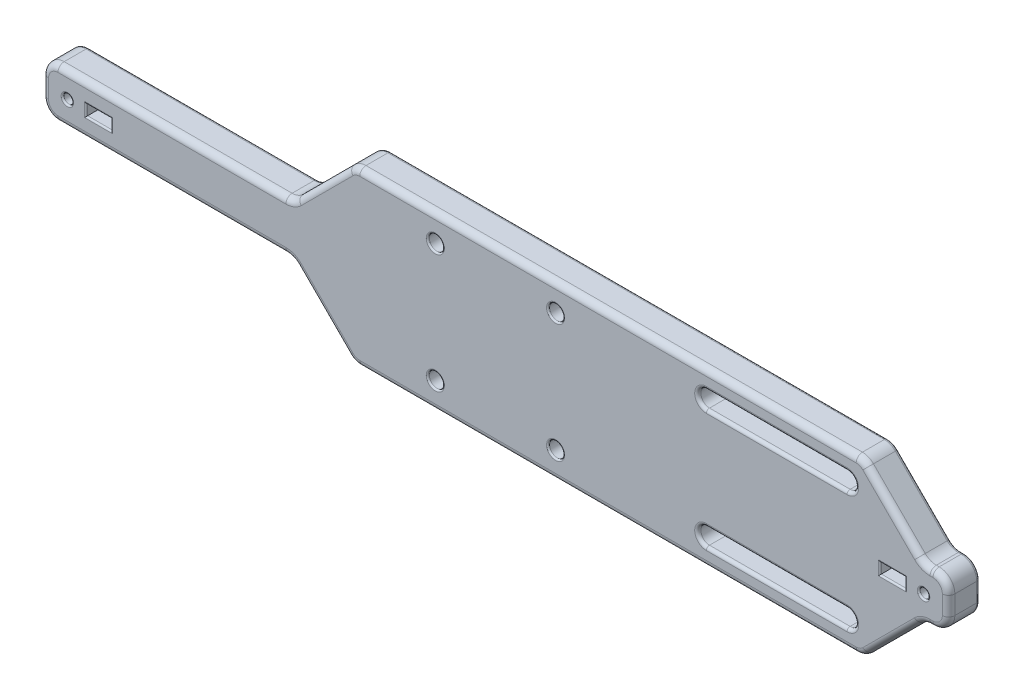
from build123d import *

# Parameters (mm, degrees)
SKETCH1_W           = 290
SKETCH1_H           = 55
BOSS_EXTRUDE1_DEPTH = 10
SKETCH2_R           = 2.4
CUT_EXTRUDE1_DEPTH  = 8
CUT_EXTRUDE2_REACH  = 12
CUT_EXTRUDE3_REACH  = 12
SKETCH6_R           = 1.5
CUT_EXTRUDE4_REACH  = 12
SKETCH8_R           = 2
CUT_EXTRUDE5_DEPTH  = 8
SKETCH10_R          = 3
CUT_EXTRUDE6_DEPTH  = 6
SKETCH11_W          = 8
SKETCH11_H          = 3.5
CUT_EXTRUDE7_DEPTH  = 5
FILLET2_R           = 5
FILLET3_R           = 0.5
FILLET4_R           = 2
FILLET5_R           = 1


with BuildPart() as part:
    # Sketch1 → Boss-Extrude1 (new body)
    with BuildSketch(Plane.XY):
        Rectangle(SKETCH1_W, SKETCH1_H)
    extrude(amount=BOSS_EXTRUDE1_DEPTH)

    # Sketch2 → Cut-Extrude1 (cut)
    with BuildSketch(Plane.XY.offset(10)):
        with Locations((-19.25, 19)):
            Circle(SKETCH2_R)
        with Locations((19.25, 19)):
            Circle(SKETCH2_R)
        with Locations((19.25, -19)):
            Circle(SKETCH2_R)
        with Locations((-19.25, -19)):
            Circle(SKETCH2_R)
    extrude(amount=-CUT_EXTRUDE1_DEPTH, mode=Mode.SUBTRACT)

    # Sketch5 → Cut-Extrude2 (cut, up to next)
    with BuildSketch(Plane.XY.offset(10), mode=Mode.PRIVATE) as cut_extrude2_sk1:
        with BuildLine():
            Line((67.5, 21.75), (112.5, 21.75))
            ThreePointArc((112.5, 21.75), (115.25, 19), (112.5, 16.25))
            Line((112.5, 16.25), (67.5, 16.25))
            ThreePointArc((67.5, 16.25), (64.75, 19), (67.5, 21.75))
        make_face()
    cut_extrude2_tool1 = extrude(cut_extrude2_sk1.sketch, amount=-CUT_EXTRUDE2_REACH, mode=Mode.PRIVATE) & part.part
    add(cut_extrude2_tool1.solids().sort_by_distance((90, 19, 10))[0], mode=Mode.SUBTRACT)
    # Sketch5 → Cut-Extrude2 (cut, up to next)
    with BuildSketch(Plane.XY.offset(10), mode=Mode.PRIVATE) as cut_extrude2_sk2:
        with BuildLine():
            Line((67.5, -21.75), (112.5, -21.75))
            ThreePointArc((112.5, -21.75), (115.25, -19), (112.5, -16.25))
            Line((112.5, -16.25), (67.5, -16.25))
            ThreePointArc((67.5, -16.25), (64.75, -19), (67.5, -21.75))
        make_face()
    cut_extrude2_tool2 = extrude(cut_extrude2_sk2.sketch, amount=-CUT_EXTRUDE2_REACH, mode=Mode.PRIVATE) & part.part
    add(cut_extrude2_tool2.solids().sort_by_distance((90, -19, 10))[0], mode=Mode.SUBTRACT)

    # Sketch6 → Cut-Extrude3 (cut, up to next)
    with BuildSketch(Plane.XY.offset(10), mode=Mode.PRIVATE) as cut_extrude3_sk1:
        with Locations((137, 0)):
            Circle(SKETCH6_R)
    cut_extrude3_tool1 = extrude(cut_extrude3_sk1.sketch, amount=-CUT_EXTRUDE3_REACH, mode=Mode.PRIVATE) & part.part
    add(cut_extrude3_tool1.solids().sort_by_distance((137, 0, 10))[0], mode=Mode.SUBTRACT)
    # Sketch6 → Cut-Extrude3 (cut, up to next)
    with BuildSketch(Plane.XY.offset(10), mode=Mode.PRIVATE) as cut_extrude3_sk2:
        with Locations((-137, 0)):
            Circle(SKETCH6_R)
    cut_extrude3_tool2 = extrude(cut_extrude3_sk2.sketch, amount=-CUT_EXTRUDE3_REACH, mode=Mode.PRIVATE) & part.part
    add(cut_extrude3_tool2.solids().sort_by_distance((-137, 0, 10))[0], mode=Mode.SUBTRACT)

    # Sketch7 → Cut-Extrude4 (cut, up to next)
    with BuildSketch(Plane.XY.offset(10), mode=Mode.PRIVATE) as cut_extrude4_sk1:
        Polygon((-145, 8), (-65, 8), (-45.5, 27.5), (-145, 27.5), align=None)
    cut_extrude4_tool1 = extrude(cut_extrude4_sk1.sketch, amount=-CUT_EXTRUDE4_REACH, mode=Mode.PRIVATE) & part.part
    add(cut_extrude4_tool1.solids().sort_by_distance((-99.948468, 18.103064, 10))[0], mode=Mode.SUBTRACT)
    # Sketch7 → Cut-Extrude4 (cut, up to next)
    with BuildSketch(Plane.XY.offset(10), mode=Mode.PRIVATE) as cut_extrude4_sk2:
        Polygon((-65, -8), (-45.5, -27.5), (-145, -27.5), (-145, -8), align=None)
    cut_extrude4_tool2 = extrude(cut_extrude4_sk2.sketch, amount=-CUT_EXTRUDE4_REACH, mode=Mode.PRIVATE) & part.part
    add(cut_extrude4_tool2.solids().sort_by_distance((-99.948468, -18.103064, 10))[0], mode=Mode.SUBTRACT)
    # Sketch7 → Cut-Extrude4 (cut, up to next)
    with BuildSketch(Plane.XY.offset(10), mode=Mode.PRIVATE) as cut_extrude4_sk3:
        Polygon((117.5, 27.5), (137, 8), (145, 8), (145, 27.5), align=None)
    cut_extrude4_tool3 = extrude(cut_extrude4_sk3.sketch, amount=-CUT_EXTRUDE4_REACH, mode=Mode.PRIVATE) & part.part
    add(cut_extrude4_tool3.solids().sort_by_distance((135.232394, 19.535211, 10))[0], mode=Mode.SUBTRACT)
    # Sketch7 → Cut-Extrude4 (cut, up to next)
    with BuildSketch(Plane.XY.offset(10), mode=Mode.PRIVATE) as cut_extrude4_sk4:
        Polygon((117.5, -27.5), (145, -27.5), (145, -8), (137, -8), align=None)
    cut_extrude4_tool4 = extrude(cut_extrude4_sk4.sketch, amount=-CUT_EXTRUDE4_REACH, mode=Mode.PRIVATE) & part.part
    add(cut_extrude4_tool4.solids().sort_by_distance((135.232394, -19.535211, 10))[0], mode=Mode.SUBTRACT)

    # Sketch8 → Cut-Extrude5 (cut)
    with BuildSketch(Plane(origin=(0, 0, 0), x_dir=(-1, 0, 0), z_dir=(0, 0, -1))):
        with Locations((35, 15)):
            Circle(SKETCH8_R)
        with Locations((35, -15)):
            Circle(SKETCH8_R)
        with Locations((-35, -15)):
            Circle(SKETCH8_R)
        with Locations((-35, 15)):
            Circle(SKETCH8_R)
    extrude(amount=-CUT_EXTRUDE5_DEPTH, mode=Mode.SUBTRACT)

    # Sketch10 → Cut-Extrude6 (cut)
    with BuildSketch(Plane(origin=(0, 0, 0), x_dir=(-1, 0, 0), z_dir=(0, 0, -1))):
        with Locations((-137, 0)):
            Circle(SKETCH10_R)
        with Locations((137, 0)):
            Circle(SKETCH10_R)
    extrude(amount=-CUT_EXTRUDE6_DEPTH, mode=Mode.SUBTRACT)

    # Sketch11 → Cut-Extrude7 (cut)
    with BuildSketch(Plane.XY.offset(10)):
        with Locations((-127, 0)):
            Rectangle(SKETCH11_W, SKETCH11_H)
        with Locations((127, 0)):
            Rectangle(SKETCH11_W, SKETCH11_H)
    extrude(amount=-CUT_EXTRUDE7_DEPTH, mode=Mode.SUBTRACT)

    # Fillet2
    fillet2_edges = [part.edges().sort_by_distance(p)[0] for p in [
        (117.5, -27.5, 5),
        (137, -8, 5),
        (145, -8, 5),
        (-145, 8, 5),
        (-45.5, 27.5, 5),
        (-65, 8, 5),
        (-145, -8, 5),
        (-65, -8, 5),
        (-45.5, -27.5, 5),
        (117.5, 27.5, 5),
        (145, 8, 5),
        (137, 8, 5),
    ]]
    fillet(fillet2_edges, radius=FILLET2_R)

    # Fillet3
    fillet3_edges = [part.edges().sort_by_distance(p)[0] for p in [
        (37, 15, 0),
        (37, -15, 0),
        (-33, -15, 0),
        (-33, 15, 0),
        (140, 0, 0),
        (135.5, 0, 6),
        (-134, 0, 0),
        (-138.5, 0, 6),
        (-123, 0, 10),
        (-127, 1.75, 10),
        (-131, 0, 10),
        (-127, -1.75, 10),
        (131, 0, 10),
        (127, 1.75, 10),
        (123, 0, 10),
        (127, -1.75, 10),
        (-21.65, -19, 10),
        (16.85, -19, 10),
        (16.85, 19, 10),
        (-21.65, 19, 10),
        (135.5, 0, 10),
        (-138.5, 0, 10),
    ]]
    fillet(fillet3_edges, radius=FILLET3_R)

    # Fillet4
    fillet4_edges = [part.edges().sort_by_distance(p)[0] for p in [
        (-103.535533906, -8, 10),
        (-55.25, -17.75, 10),
        (-145, 0, 10),
        (36, -27.5, 10),
        (127.25, -17.75, 10),
        (139.535533906, -8, 10),
        (145, 0, 10),
        (139.535533906, 8, 10),
        (127.25, 17.75, 10),
        (36, 27.5, 10),
        (-55.25, 17.75, 10),
        (-103.535533906, 8, 10),
        (-143.535533906, -6.535533906, 10),
        (-143.535533906, 6.535533906, 10),
        (-45.34234935, 27.119397663, 10),
        (117.34234935, 27.119397663, 10),
        (143.535533906, 6.535533906, 10),
        (143.535533906, -6.535533906, 10),
        (117.34234935, -27.119397663, 10),
        (-45.34234935, -27.119397663, 10),
        (-65.15765065, -8.380602337, 10),
        (137.15765065, -8.380602337, 10),
        (137.15765065, 8.380602337, 10),
        (-65.15765065, 8.380602337, 10),
    ]]
    fillet(fillet4_edges, radius=FILLET4_R)

    # Fillet5
    fillet5_edges = [part.edges().sort_by_distance(p)[0] for p in [
        (-103.535533906, -8, 0),
        (-55.25, -17.75, 0),
        (36, -27.5, 0),
        (-145, 0, 0),
        (-103.535533906, 8, 0),
        (-55.25, 17.75, 0),
        (36, 27.5, 0),
        (127.25, 17.75, 0),
        (139.535533906, 8, 0),
        (145, 0, 0),
        (139.535533906, -8, 0),
        (127.25, -17.75, 0),
        (-143.535533906, -6.535533906, 0),
        (-143.535533906, 6.535533906, 0),
        (-45.34234935, 27.119397663, 0),
        (117.34234935, 27.119397663, 0),
        (143.535533906, 6.535533906, 0),
        (143.535533906, -6.535533906, 0),
        (117.34234935, -27.119397663, 0),
        (-45.34234935, -27.119397663, 0),
        (-65.15765065, -8.380602337, 0),
        (137.15765065, -8.380602337, 0),
        (137.15765065, 8.380602337, 0),
        (-65.15765065, 8.380602337, 0),
        (64.75, 19, 0),
        (90, 21.75, 0),
        (115.25, 19, 0),
        (90, 16.25, 0),
        (64.75, 19, 10),
        (90, 16.25, 10),
        (115.25, 19, 10),
        (90, 21.75, 10),
        (64.75, -19, 0),
        (90, -16.25, 0),
        (115.25, -19, 0),
        (90, -21.75, 0),
        (64.75, -19, 10),
        (90, -21.75, 10),
        (115.25, -19, 10),
        (90, -16.25, 10),
    ]]
    fillet(fillet5_edges, radius=FILLET5_R)


solid = part.part
